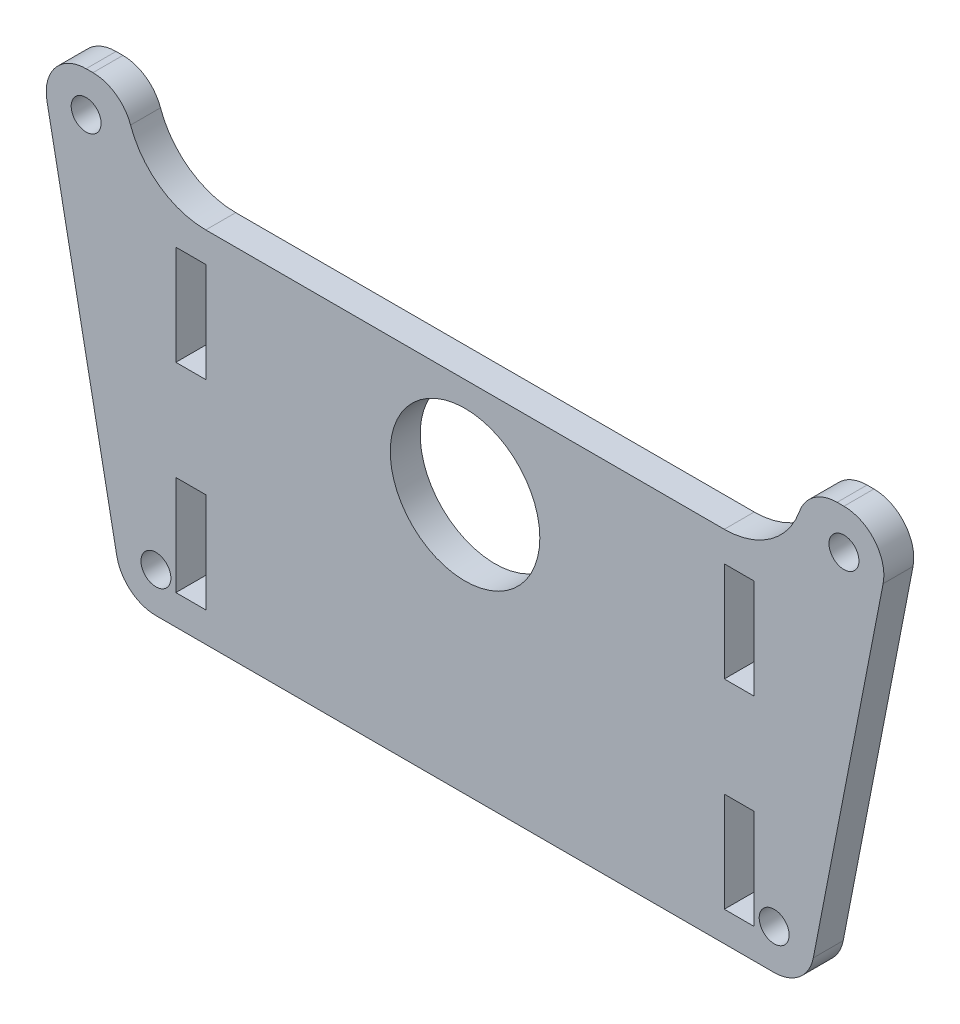
from build123d import *

# Parameters (mm, degrees)
SKETCH1_R           = 1.5
SKETCH1_R_2         = 7.5
SKETCH1_W           = 3
SKETCH1_H           = 10
BOSS_EXTRUDE1_DEPTH = 3


with BuildPart() as part:
    # Sketch1 → Boss-Extrude1 (new body)
    with BuildSketch(Plane.XY):
        with BuildLine():
            Line((-41.926461559, 19.115471746), (-34.926461559, -16.884528254))
            ThreePointArc((-34.926461559, -16.884528254), (-33.544217508, -19.207626568), (-31, -20.121049617))
            Line((-31, -20.121049617), (31, -20.121049617))
            ThreePointArc((31, -20.121049617), (33.544217508, -19.207626568), (34.926461559, -16.884528254))
            Line((34.926461559, -16.884528254), (41.926461559, 19.115471746))
            ThreePointArc((41.926461559, 19.115471746), (41.086576951, 22.42316789), (38, 23.878950383))
            Line((38, 23.878950383), (37.313708499, 23.878950383))
            ThreePointArc((37.313708499, 23.878950383), (35.004307422, 23.144936706), (33.542472333, 21.212283716))
            ThreePointArc((33.542472333, 21.212283716), (30.618802154, 17.346977735), (26, 15.878950383))
            Line((26, 15.878950383), (-26, 15.878950383))
            ThreePointArc((-26, 15.878950383), (-30.618802154, 17.346977735), (-33.542472333, 21.212283716))
            ThreePointArc((-33.542472333, 21.212283716), (-35.004307422, 23.144936706), (-37.313708499, 23.878950383))
            Line((-37.313708499, 23.878950383), (-38, 23.878950383))
            ThreePointArc((-38, 23.878950383), (-41.086576951, 22.42316789), (-41.926461559, 19.115471746))
        make_face()
        with Locations((38, 19.878950383)):
            Circle(SKETCH1_R, mode=Mode.SUBTRACT)
        with Locations((-38, 19.878950383)):
            Circle(SKETCH1_R, mode=Mode.SUBTRACT)
        with Locations((31, -16.121049617)):
            Circle(SKETCH1_R, mode=Mode.SUBTRACT)
        with Locations((-31, -16.121049617)):
            Circle(SKETCH1_R, mode=Mode.SUBTRACT)
        with Locations((0, 5.878950383)):
            Circle(SKETCH1_R_2, mode=Mode.SUBTRACT)
        with Locations((-27.5, 7.878950383)):
            Rectangle(SKETCH1_W, SKETCH1_H, mode=Mode.SUBTRACT)
        with Locations((-27.5, -12.121049617)):
            Rectangle(SKETCH1_W, SKETCH1_H, mode=Mode.SUBTRACT)
        with Locations((27.5, -12.121049617)):
            Rectangle(SKETCH1_W, SKETCH1_H, mode=Mode.SUBTRACT)
        with Locations((27.5, 7.878950383)):
            Rectangle(SKETCH1_W, SKETCH1_H, mode=Mode.SUBTRACT)
    extrude(amount=BOSS_EXTRUDE1_DEPTH)


solid = part.part
